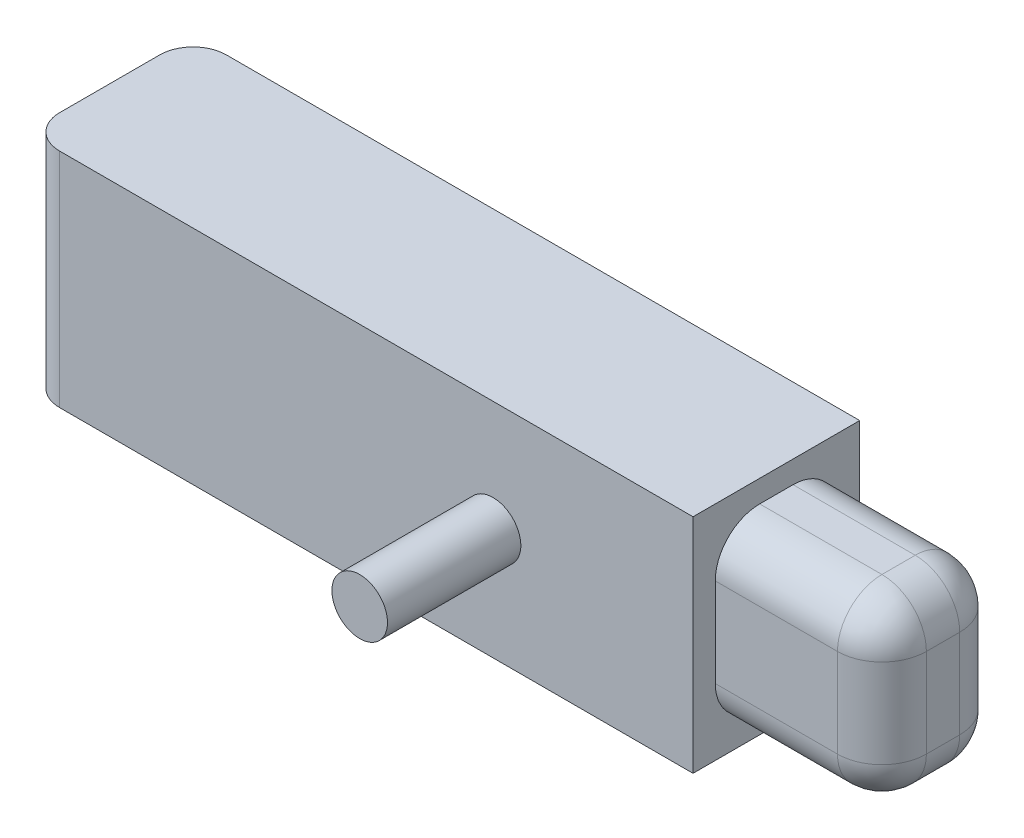
from build123d import *

# Parameters (mm, degrees)
CROQUIS1_W              = 60
CROQUIS1_H              = 15
SALIENTE_EXTRUIR1_DEPTH = 20
CROQUIS2_R              = 2.5
SALIENTE_EXTRUIR2_DEPTH = 12
CROQUIS3_W              = 11
CROQUIS3_H              = 16
SALIENTE_EXTRUIR3_DEPTH = 15
REDONDEO1_R             = 4
REDONDEO2_R             = 4
REDONDEO3_R             = 3
ESCALA1_SCALE           = 2


with BuildPart() as part:
    # Croquis1 → Saliente-Extruir1 (new body)
    with BuildSketch(Plane(origin=(0, 0, 0), x_dir=(1, 0, 0), z_dir=(0, 1, 0))):
        Rectangle(CROQUIS1_W, CROQUIS1_H)
    extrude(amount=SALIENTE_EXTRUIR1_DEPTH)

    # Croquis2 → Saliente-Extruir2 (add)
    with BuildSketch(Plane.XY.offset(7.5)):
        with Locations((12, 10)):
            Circle(CROQUIS2_R)
    extrude(amount=SALIENTE_EXTRUIR2_DEPTH)

    # Croquis3 → Saliente-Extruir3 (add)
    with BuildSketch(Plane(origin=(30, 0, 0), x_dir=(0, 0, -1), z_dir=(1, 0, 0))):
        with Locations((0, 10)):
            Rectangle(CROQUIS3_W, CROQUIS3_H)
    extrude(amount=SALIENTE_EXTRUIR3_DEPTH)

    # Redondeo1
    redondeo1_edges = [part.edges().sort_by_distance(p)[0] for p in [
        (37.5, 18, 5.5),
        (37.5, 2, 5.5),
        (37.5, 2, -5.5),
        (37.5, 18, -5.5),
    ]]
    fillet(redondeo1_edges, radius=REDONDEO1_R)

    # Redondeo2
    redondeo2_edges = [part.edges().sort_by_distance(p)[0] for p in [
        (45, 18, 0),
        (45, 10, -5.5),
        (45, 10, 5.5),
        (45, 2, 0),
        (45, 16.828427125, 4.328427125),
        (45, 3.171572875, 4.328427125),
        (45, 3.171572875, -4.328427125),
        (45, 16.828427125, -4.328427125),
    ]]
    fillet(redondeo2_edges, radius=REDONDEO2_R)

    # Redondeo3
    redondeo3_edges = [part.edges().sort_by_distance(p)[0] for p in [
        (-30, 10, -7.5),
        (-30, 10, 7.5),
    ]]
    fillet(redondeo3_edges, radius=REDONDEO3_R)


with BuildPart() as part_1:
    # Escala1: scaled about (4.405278124, 10, 0.15554504)
    add(part.part.scale(ESCALA1_SCALE).moved(Location((-4.405278124, -10, -0.15554504))))


solid = part_1.part
